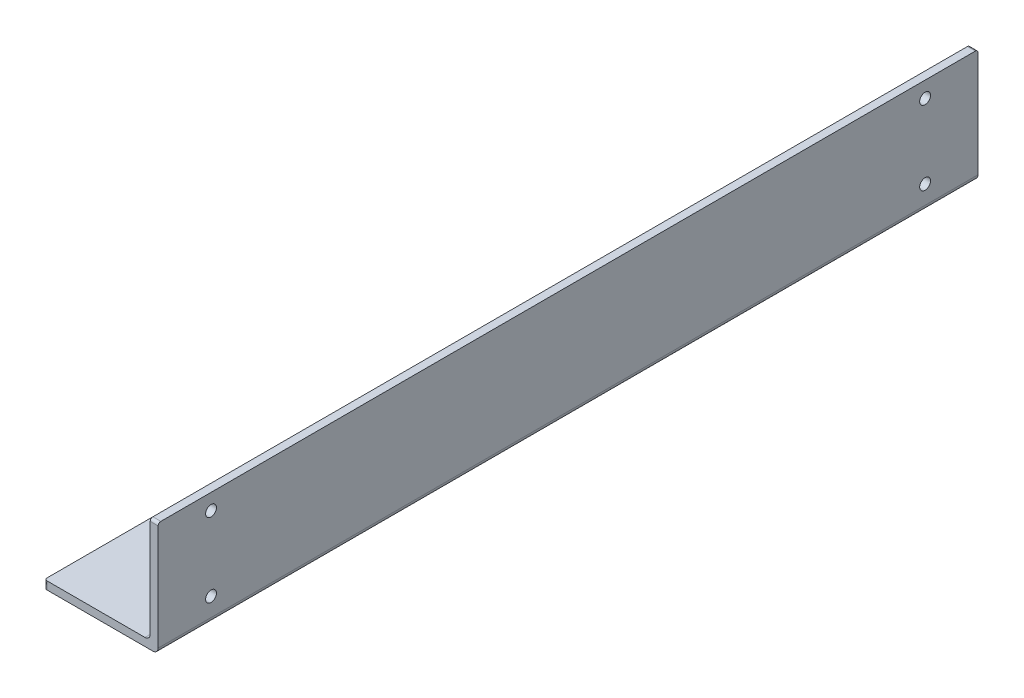
from build123d import *

# Parameters (mm, degrees)
SKETCH_1_W          = 310
SKETCH_1_H          = 43
EXTRUDE_1_DEPTH     = 3
SKETCH_2_W          = 40
SKETCH_2_H          = 310
EXTRUDE_2_DEPTH     = 3
FILLET_1_R          = 2
FILLET_2_R          = 2
FILLET_3_R          = 1
SKETCH_3_R          = 2.05
CUT_EXTRUDE_1_DEPTH = 44


with BuildPart() as part:
    # 草图1 → 凸台-拉伸1 (new body)
    with BuildSketch(Plane(origin=(0, 0, 0), x_dir=(0, 0, -1), z_dir=(1, 0, 0))):
        with Locations((155, 21.5)):
            Rectangle(SKETCH_1_W, SKETCH_1_H)
    extrude(amount=EXTRUDE_1_DEPTH)

    # 草图2 → 凸台-拉伸2 (add)
    with BuildSketch(Plane(origin=(0, 0, 0), x_dir=(1, 0, 0), z_dir=(0, 1, 0))):
        with Locations((-20, 155)):
            Rectangle(SKETCH_2_W, SKETCH_2_H)
    extrude(amount=EXTRUDE_2_DEPTH)

    # 圆角1
    fillet_1_edges = [part.edges().sort_by_distance(p)[0] for p in [
        (3, 0, -155),
    ]]
    fillet(fillet_1_edges, radius=FILLET_1_R)

    # 圆角2
    fillet_2_edges = [part.edges().sort_by_distance(p)[0] for p in [
        (0, 3, -155),
    ]]
    fillet(fillet_2_edges, radius=FILLET_2_R)

    # 圆角3
    fillet_3_edges = [part.edges().sort_by_distance(p)[0] for p in [
        (-40, 1.5, -310),
        (-40, 1.5, 0),
        (1.5, 43, 0),
        (1.5, 43, -310),
    ]]
    fillet(fillet_3_edges, radius=FILLET_3_R)

    # 草图3 → 切除-拉伸1 (cut, through all)
    with BuildSketch(Plane(origin=(3, 0, 0), x_dir=(0, 0, -1), z_dir=(1, 0, 0))):
        with Locations((20, 37)):
            Circle(SKETCH_3_R)
        with Locations((20, 9)):
            Circle(SKETCH_3_R)
        with Locations((290, 9)):
            Circle(SKETCH_3_R)
        with Locations((290, 37)):
            Circle(SKETCH_3_R)
    extrude(amount=-CUT_EXTRUDE_1_DEPTH, mode=Mode.SUBTRACT)


solid = part.part
